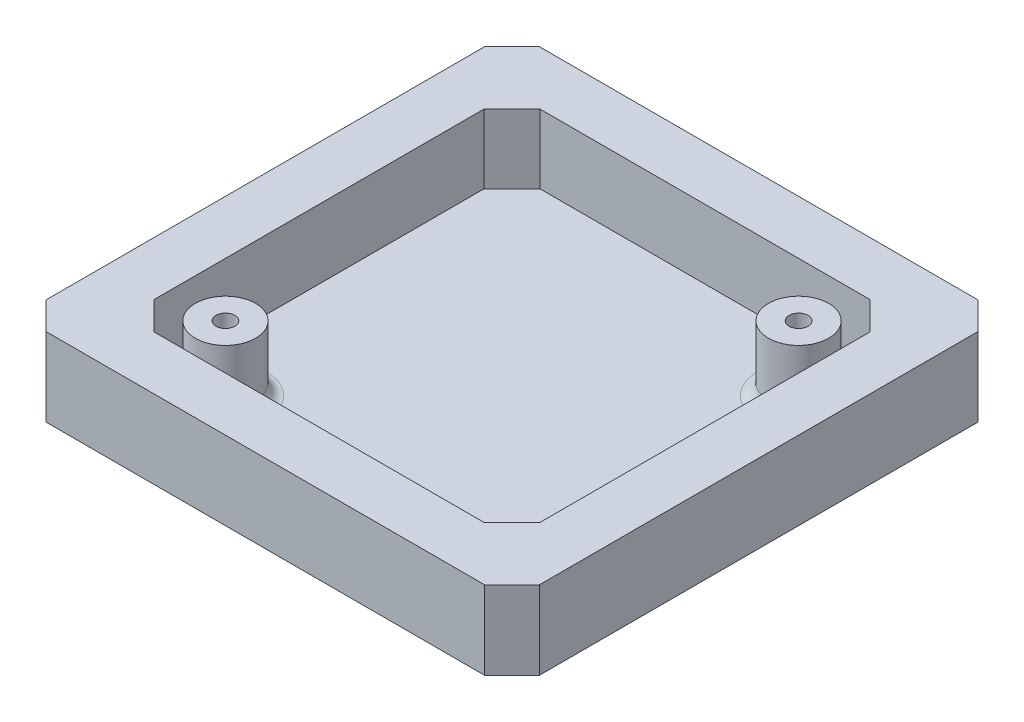
from build123d import *

# Parameters (mm, degrees)
SKETCH1_W           = 90
SKETCH1_H           = 90
BOSS_EXTRUDE1_DEPTH = 14.3
SKETCH2_W           = 70
SKETCH2_H           = 70
CUT_EXTRUDE1_DEPTH  = 12.6
SKETCH3_R           = 1.725
CUT_EXTRUDE2_DEPTH  = 2.7
CHAMFER1_SIZE       = 5
SKETCH4_R           = 5.5
SKETCH4_R_2         = 1.725
BOSS_EXTRUDE2_DEPTH = 11.8
FILLET1_R           = 2
SKETCH5_R           = 3.25
CUT_EXTRUDE3_DEPTH  = 4
CHAMFER2_SIZE       = 5
CUT_EXTRUDE4_DEPTH  = 13.6


with BuildPart() as part:
    # Sketch1 → Boss-Extrude1 (new body)
    with BuildSketch(Plane(origin=(0, 0, 0), x_dir=(1, 0, 0), z_dir=(0, 1, 0))):
        with Locations((45, 45)):
            Rectangle(SKETCH1_W, SKETCH1_H)
    extrude(amount=BOSS_EXTRUDE1_DEPTH)

    # Sketch2 → Cut-Extrude1 (cut)
    with BuildSketch(Plane(origin=(0, 14.3, 0), x_dir=(1, 0, 0), z_dir=(0, 1, 0))):
        with Locations((45, 45)):
            Rectangle(SKETCH2_W, SKETCH2_H)
    extrude(amount=-CUT_EXTRUDE1_DEPTH, mode=Mode.SUBTRACT)

    # Sketch3 → Cut-Extrude2 (cut, through all)
    with BuildSketch(Plane(origin=(0, 1.7, 0), x_dir=(1, 0, 0), z_dir=(0, 1, 0))):
        with Locations((18.863961034, 18.863961034)):
            Circle(SKETCH3_R)
        with Locations((71.136038966, 71.136038966)):
            Circle(SKETCH3_R)
    extrude(amount=-CUT_EXTRUDE2_DEPTH, mode=Mode.SUBTRACT)

    # Chamfer1
    chamfer1_edges = [part.edges().sort_by_distance(p)[0] for p in [
        (0, 7.15, -90),
        (90, 7.15, -90),
        (90, 7.15, 0),
        (0, 7.15, 0),
    ]]
    chamfer(chamfer1_edges, length=CHAMFER1_SIZE)

    # Sketch4 → Boss-Extrude2 (add)
    with BuildSketch(Plane(origin=(0, 1.7, 0), x_dir=(1, 0, 0), z_dir=(0, 1, 0))):
        with Locations((71.136038966, 71.136038966)):
            Circle(SKETCH4_R)
        with Locations((71.136038966, 71.136038966)):
            Circle(SKETCH4_R_2, mode=Mode.SUBTRACT)
        with Locations((18.863961034, 18.863961034)):
            Circle(SKETCH4_R)
        with Locations((18.863961034, 18.863961034)):
            Circle(SKETCH4_R_2, mode=Mode.SUBTRACT)
    extrude(amount=BOSS_EXTRUDE2_DEPTH)

    # Fillet1
    fillet1_edges = [part.edges().sort_by_distance(p)[0] for p in [
        (65.636038966, 1.7, -71.136038966),
        (13.363961034, 1.7, -18.863961034),
    ]]
    fillet(fillet1_edges, radius=FILLET1_R)

    # Sketch5 → Cut-Extrude3 (cut)
    with BuildSketch(Plane.XZ):
        with Locations((18.863961034, -18.863961034)):
            Circle(SKETCH5_R)
        with Locations((71.136038966, -71.136038966)):
            Circle(SKETCH5_R)
    extrude(amount=-CUT_EXTRUDE3_DEPTH, mode=Mode.SUBTRACT)

    # Chamfer2
    chamfer2_edges = [part.edges().sort_by_distance(p)[0] for p in [
        (10, 8, -10),
        (10, 8, -80),
        (80, 8, -80),
        (80, 8, -10),
    ]]
    chamfer(chamfer2_edges, length=CHAMFER2_SIZE)

    # Sketch6 → Cut-Extrude4 (cut, through all)
    with BuildSketch(Plane(origin=(0, 1.7, 0), x_dir=(1, 0, 0), z_dir=(0, 1, 0))):
        Polygon((80.2, 14.917157288), (80.2, 75.082842712), (75.082842712, 80.2), (14.917157288, 80.2), (9.8, 75.082842712), (9.8, 14.917157288), (14.917157288, 9.8), (75.082842712, 9.8), align=None)
        Polygon((15, 10), (10, 15), (10, 75), (15, 80), (75, 80), (80, 75), (80, 15), (75, 10), align=None, mode=Mode.SUBTRACT)
    extrude(amount=CUT_EXTRUDE4_DEPTH, mode=Mode.SUBTRACT)


solid = part.part
